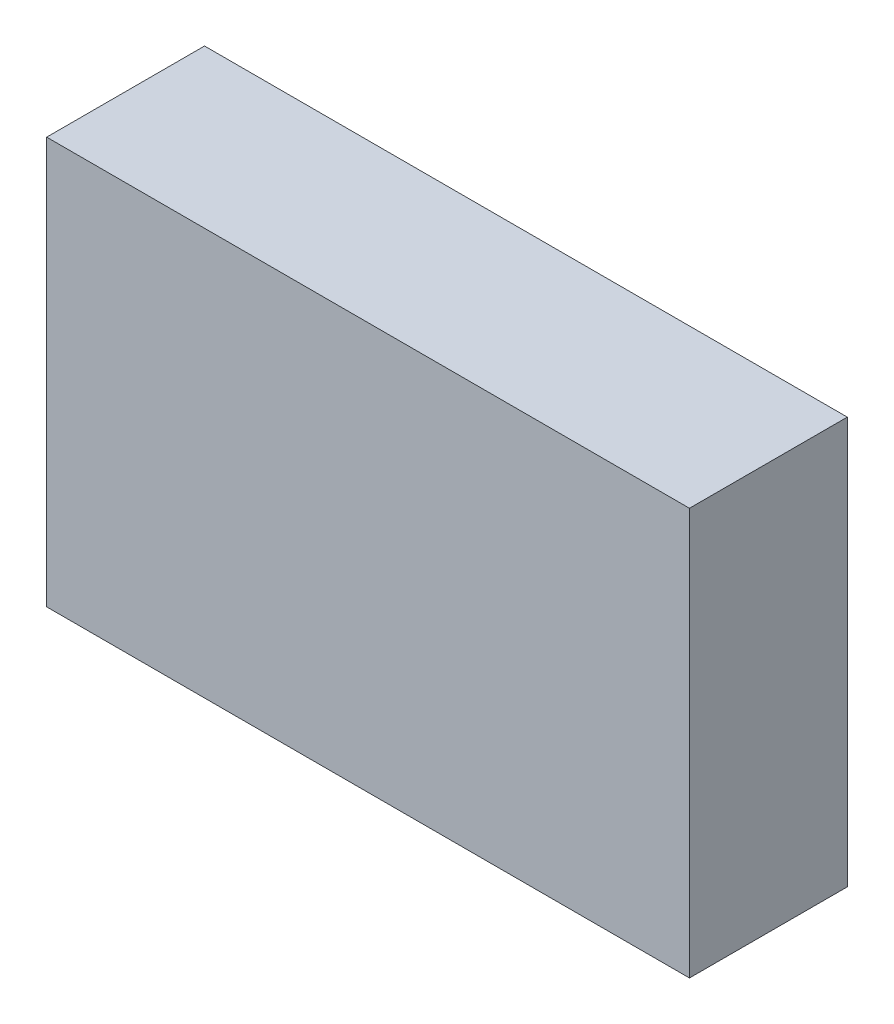
from build123d import *

# Parameters (mm, degrees)
SKETCH1_W           = 100.33
SKETCH1_H           = 63.5
BOSS_EXTRUDE1_DEPTH = 24.638
SKETCH3_W           = 10.16
SKETCH3_H           = 8.89
SKETCH3_W_2         = 13.97
SKETCH3_H_2         = 6.604
CUT_EXTRUDE1_DEPTH  = 25.4
SKETCH4_W           = 10.414
SKETCH4_H           = 15.24
BOSS_EXTRUDE2_DEPTH = 5.08


with BuildPart() as part:
    # Sketch1 → Boss-Extrude1 (new body)
    with BuildSketch(Plane.XY):
        Rectangle(SKETCH1_W, SKETCH1_H)
    extrude(amount=BOSS_EXTRUDE1_DEPTH)

    # Sketch3 → Cut-Extrude1 (cut)
    with BuildSketch(Plane.ZY.offset(50.165)):
        with Locations((13.97, 18.415)):
            Rectangle(SKETCH3_W, SKETCH3_H)
        with Locations((12.065, 6.604)):
            Rectangle(SKETCH3_W_2, SKETCH3_H_2)
    extrude(amount=-CUT_EXTRUDE1_DEPTH, mode=Mode.SUBTRACT)

    # Sketch4 → Boss-Extrude2 (add)
    with BuildSketch(Plane.ZY.offset(50.165)):
        with Locations((12.319, -13.97)):
            Rectangle(SKETCH4_W, SKETCH4_H)
    extrude(amount=BOSS_EXTRUDE2_DEPTH)


solid = part.part
